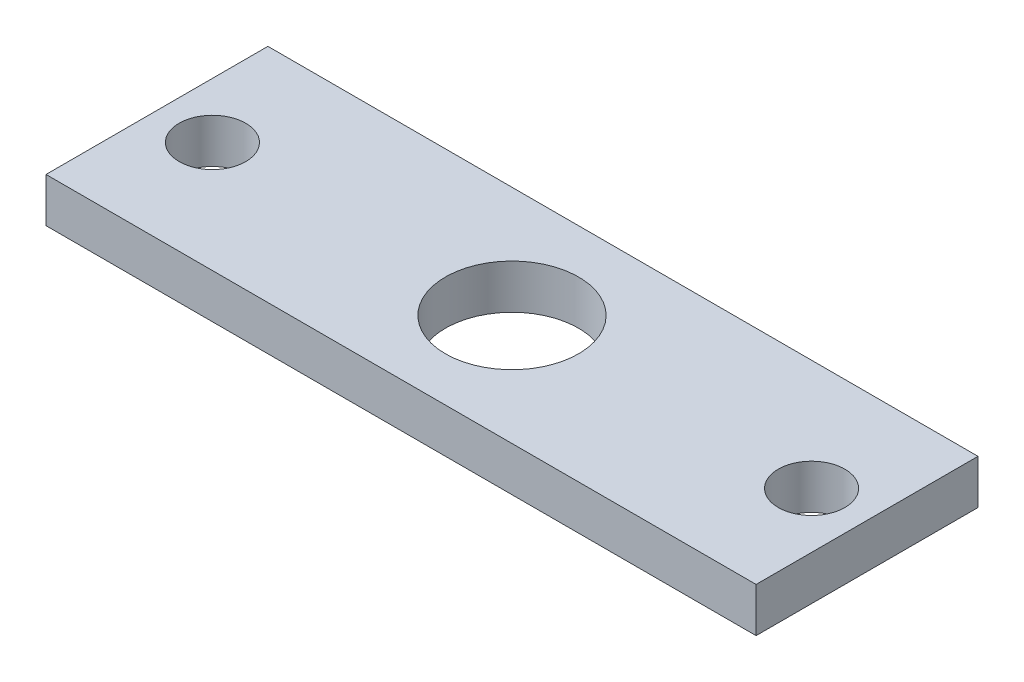
from build123d import *

# Parameters (mm, degrees)
SKETCH1_W           = 32
SKETCH1_H           = 10
BOSS_EXTRUDE1_DEPTH = 2
SKETCH2_R           = 1.5
SKETCH2_R_2         = 3
CUT_EXTRUDE1_DEPTH  = 3


with BuildPart() as part:
    # Sketch1 → Boss-Extrude1 (new body)
    with BuildSketch(Plane(origin=(0, 0, 0), x_dir=(1, 0, 0), z_dir=(0, 1, 0))):
        with Locations((-9.333333333, 0.131578947)):
            Rectangle(SKETCH1_W, SKETCH1_H)
    extrude(amount=BOSS_EXTRUDE1_DEPTH)

    # Sketch2 → Cut-Extrude1 (cut, through all)
    with BuildSketch(Plane(origin=(0, 2, 0), x_dir=(1, 0, 0), z_dir=(0, 1, 0))):
        with Locations((-22.833333333, 0.131578947)):
            Circle(SKETCH2_R)
        with Locations((4.166666667, 0.131578947)):
            Circle(SKETCH2_R)
        with Locations((-9.333333333, 0.131578947)):
            Circle(SKETCH2_R_2)
    extrude(amount=-CUT_EXTRUDE1_DEPTH, mode=Mode.SUBTRACT)


solid = part.part
